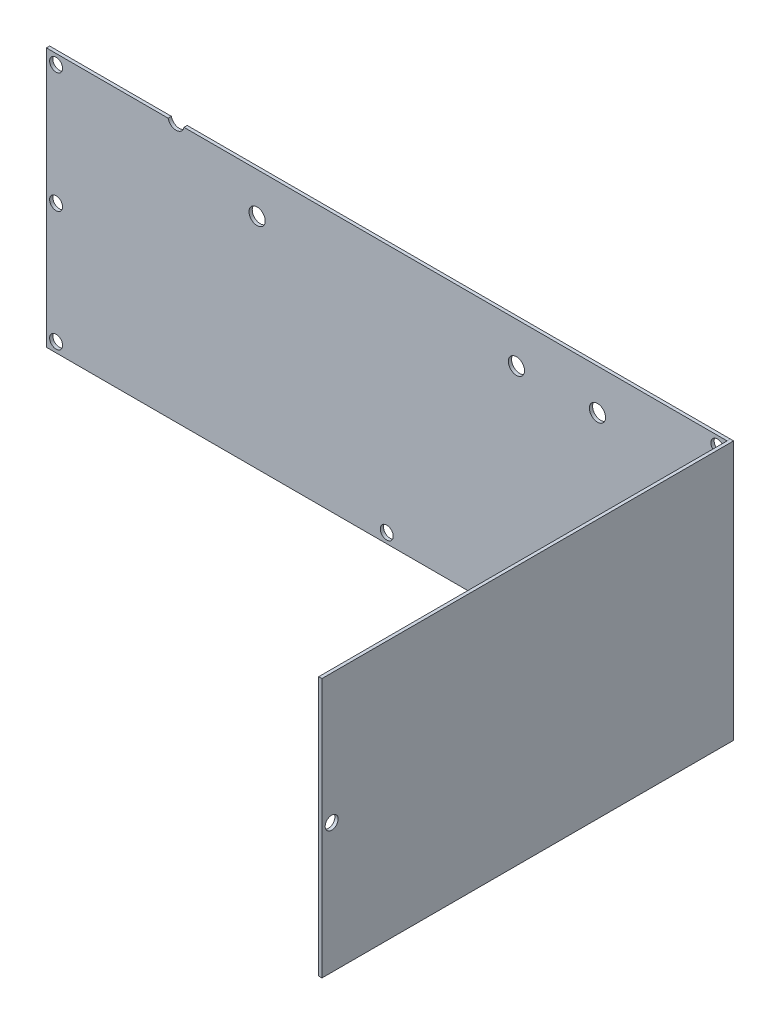
from build123d import *

# Parameters (mm, degrees)
SKETCH_1_W           = 210
SKETCH_1_H           = 80
EXTRUDE_1_DEPTH      = 1
SKETCH_2_W           = 1
SKETCH_2_H           = 80
EXTRUDE_2_DEPTH      = 126
EXTRUDE_2_DEPTH_BACK = 1
SKETCH_3_R           = 2
CUT_EXTRUDE_1_DEPTH  = 2
SKETCH_5_R           = 2
CUT_EXTRUDE_2_DEPTH  = 2
SKETCH_6_R           = 2.5
CUT_EXTRUDE_3_DEPTH  = 2


with BuildPart() as part:
    # 草图1 → 凸台-拉伸1 (new body)
    with BuildSketch(Plane.XY):
        Rectangle(SKETCH_1_W, SKETCH_1_H)
    extrude(amount=EXTRUDE_1_DEPTH)

    # 草图3 → 切除-拉伸1 (cut)
    with BuildSketch(Plane(origin=(0, 0, 0), x_dir=(-1, 0, 0), z_dir=(0, 0, -1))):
        with Locations((102, 0)):
            Circle(SKETCH_3_R)
        with Locations((102, 37)):
            Circle(SKETCH_3_R)
        with Locations((102, -37)):
            Circle(SKETCH_3_R)
        with Locations((-102, 37)):
            Circle(SKETCH_3_R)
        with Locations((0, -37)):
            Circle(SKETCH_3_R)
        with Locations((-102, -37)):
            Circle(SKETCH_3_R)
    extrude(amount=-CUT_EXTRUDE_1_DEPTH, mode=Mode.SUBTRACT)

    # 草图6 → 切除-拉伸3 (cut)
    with BuildSketch(Plane(origin=(0, 0, 0), x_dir=(-1, 0, 0), z_dir=(0, 0, -1))):
        with Locations((-65, 27.5)):
            Circle(SKETCH_6_R)
        with Locations((-40, 27.5)):
            Circle(SKETCH_6_R)
        with Locations((40, 27.5)):
            Circle(SKETCH_6_R)
        with Locations((65, 40.5)):
            Circle(SKETCH_6_R)
    extrude(amount=-CUT_EXTRUDE_3_DEPTH, mode=Mode.SUBTRACT)


with BuildPart() as body_2:
    # 草图2 → 凸台-拉伸2 (new body, two sides)
    with BuildSketch(Plane.XY.offset(1)) as extrude_2_sk:
        with Locations((105.5, 0)):
            Rectangle(SKETCH_2_W, SKETCH_2_H)
    extrude(amount=EXTRUDE_2_DEPTH)
    extrude(extrude_2_sk.sketch, amount=-EXTRUDE_2_DEPTH_BACK)

    # 草图5 → 切除-拉伸2 (cut)
    with BuildSketch(Plane(origin=(106, 0, 0), x_dir=(0, 0, -1), z_dir=(1, 0, 0))):
        with Locations((-124, 50)):
            Circle(SKETCH_5_R)
        with Locations((-64, -50)):
            Circle(SKETCH_5_R)
        with Locations((-4, -50)):
            Circle(SKETCH_5_R)
        with Locations((-124, 0)):
            Circle(SKETCH_5_R)
    extrude(amount=-CUT_EXTRUDE_2_DEPTH, mode=Mode.SUBTRACT)


solid = Compound([part.part, body_2.part])
